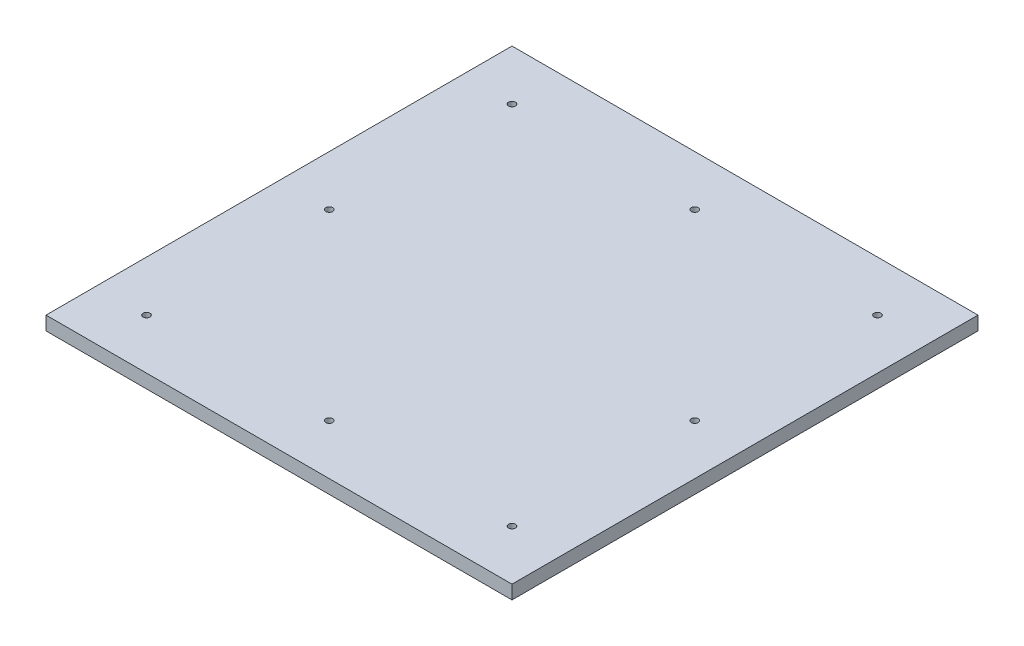
from build123d import *

# Parameters (mm, degrees)
SKETCH1_W           = 647.7
SKETCH1_H           = 647.7
SKETCH1_R           = 4.7625
BOSS_EXTRUDE1_DEPTH = 19.05


with BuildPart() as part:
    # Sketch1 → Boss-Extrude1 (new body)
    with BuildSketch(Plane(origin=(0, 0, 0), x_dir=(1, 0, 0), z_dir=(0, 1, 0))):
        with Locations((323.85, -323.85)):
            Rectangle(SKETCH1_W, SKETCH1_H)
        with Locations((69.85, -69.85)):
            Circle(SKETCH1_R, mode=Mode.SUBTRACT)
        with Locations((323.85, -69.85)):
            Circle(SKETCH1_R, mode=Mode.SUBTRACT)
        with Locations((577.85, -69.85)):
            Circle(SKETCH1_R, mode=Mode.SUBTRACT)
        with Locations((69.85, -323.85)):
            Circle(SKETCH1_R, mode=Mode.SUBTRACT)
        with Locations((577.85, -323.85)):
            Circle(SKETCH1_R, mode=Mode.SUBTRACT)
        with Locations((69.85, -577.85)):
            Circle(SKETCH1_R, mode=Mode.SUBTRACT)
        with Locations((577.85, -577.85)):
            Circle(SKETCH1_R, mode=Mode.SUBTRACT)
        with Locations((323.85, -577.85)):
            Circle(SKETCH1_R, mode=Mode.SUBTRACT)
    extrude(amount=BOSS_EXTRUDE1_DEPTH)


solid = part.part
